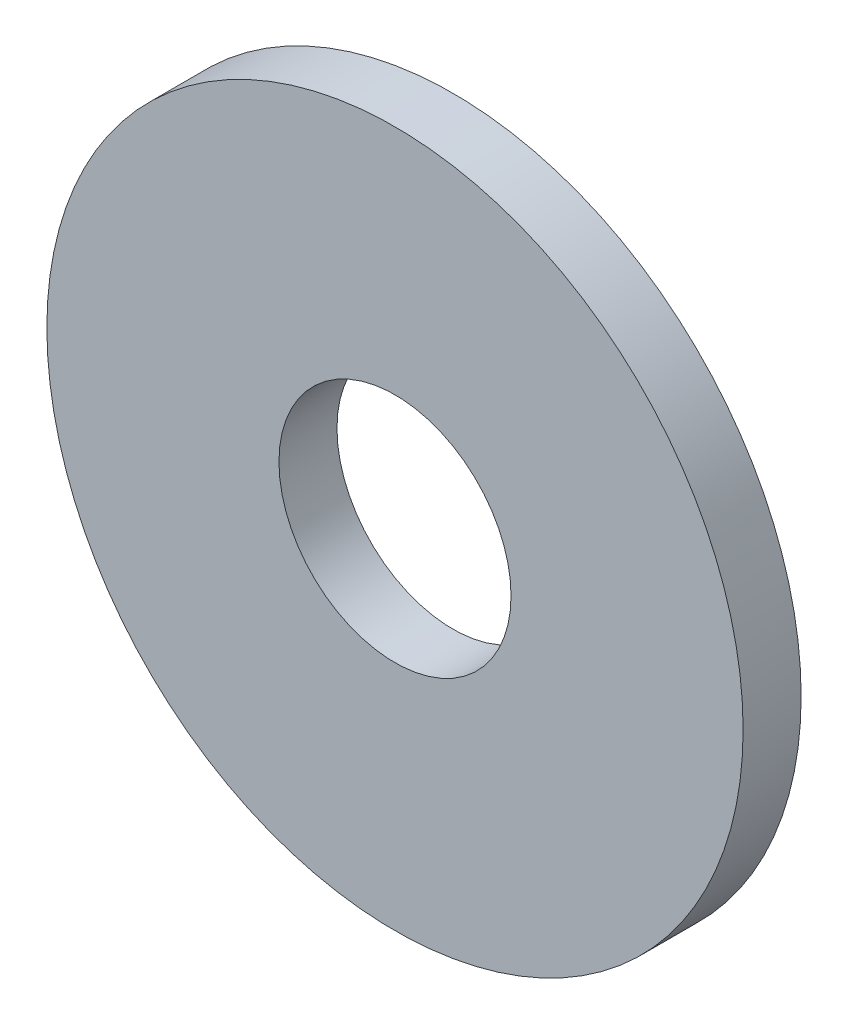
from build123d import *

# Parameters (mm, degrees)
SKETCH1_R           = 9.525
SKETCH1_R_2         = 3.175
BOSS_EXTRUDE1_DEPTH = 1.5875


with BuildPart() as part:
    # Sketch1 → Boss-Extrude1 (new body)
    with BuildSketch(Plane.XY):
        Circle(SKETCH1_R)
        Circle(SKETCH1_R_2, mode=Mode.SUBTRACT)
    extrude(amount=BOSS_EXTRUDE1_DEPTH)


solid = part.part
